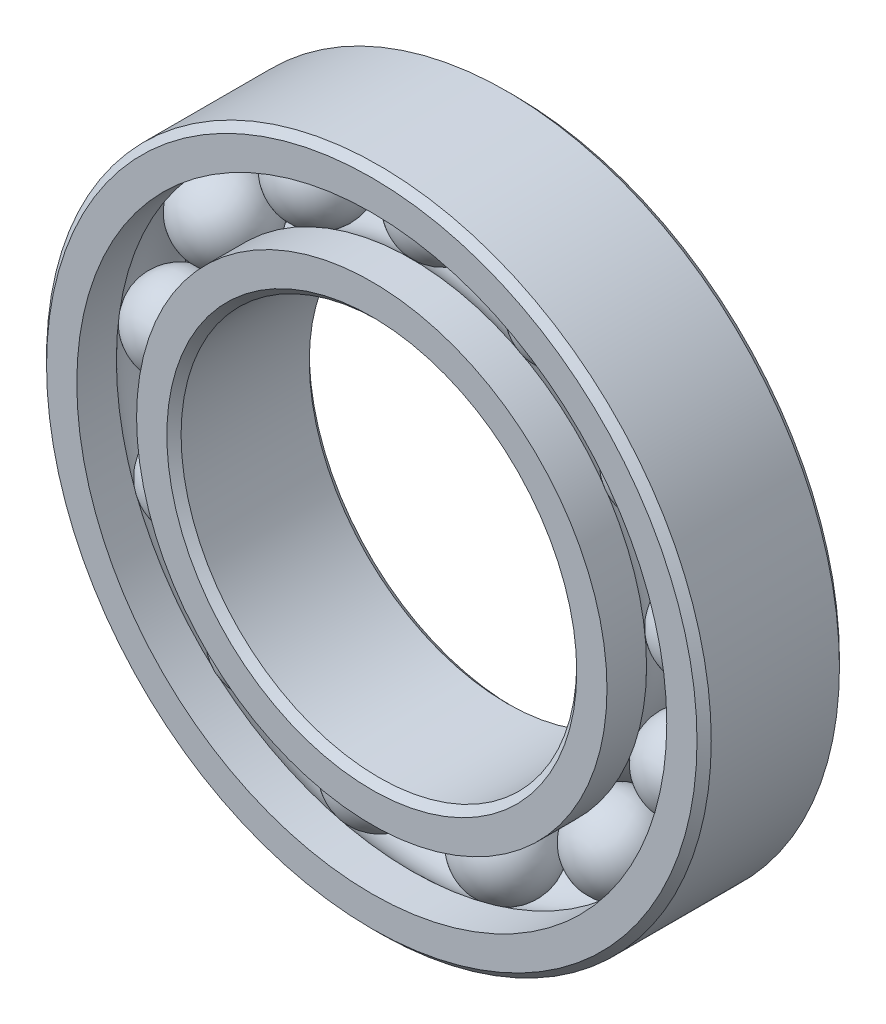
from build123d import *

# Parameters (mm, degrees)
CIRPATTERN1_COUNT = 13


with BuildPart() as part:
    # Sketch5 → Revolve1 (revolve)
    with BuildSketch(Plane(origin=(0, 0, 0), x_dir=(0, 0, -1), z_dir=(1, 0, 0))):
        with BuildLine():
            Line((4.05, 21), (-4.05, 21))
            Line((-4.05, 21), (-4.5, 20.55))
            Line((-4.5, 20.55), (-4.5, 18.638888889))
            Line((-4.5, 18.638888889), (-2, 18.638888889))
            ThreePointArc((-2, 18.638888889), (0, 19.500981867), (2, 18.638888889))
            Line((2, 18.638888889), (4.5, 18.638888889))
            Line((4.5, 18.638888889), (4.5, 20.55))
            Line((4.5, 20.55), (4.05, 21))
        make_face()
    revolve(axis=Axis((0, 0, 4.5), (0, 0, -1)))


with BuildPart() as body_2:
    # Sketch3 → Revolve3 (revolve)
    with BuildSketch(Plane(origin=(0, 0, 0), x_dir=(0, 0, -1), z_dir=(1, 0, 0))):
        with BuildLine():
            Line((-4.5, 14.861111111), (-2, 14.861111111))
            ThreePointArc((-2, 14.861111111), (0, 13.999018133), (2, 14.861111111))
            Line((2, 14.861111111), (4.5, 14.861111111))
            Line((4.5, 14.861111111), (4.5, 12.95))
            Line((4.5, 12.95), (4.05, 12.5))
            Line((4.05, 12.5), (-4.05, 12.5))
            Line((-4.05, 12.5), (-4.5, 12.95))
            Line((-4.5, 12.95), (-4.5, 14.861111111))
        make_face()
    revolve(axis=Axis((0, 0, 4.5), (0, 0, -1)))


with BuildPart() as body_3:
    # Sketch4 → Revolve4 (revolve)
    with BuildSketch(Plane(origin=(0, 0, 0), x_dir=(0, 0, -1), z_dir=(1, 0, 0))):
        with BuildLine():
            Line((-2.750981867, 16.75), (2.750981867, 16.75))
            ThreePointArc((2.750981867, 16.75), (0, 19.500981867), (-2.750981867, 16.75))
        make_face()
    revolve(axis=Axis((0, 16.75, 2.750981867), (0, 0, -1)))


with BuildPart() as cirpattern1_1:
    # CirPattern1: pattern copy
    add(body_3.part.rotate(Axis((0, 0, 0), (0, 0, 1)), 1 * 360 / CIRPATTERN1_COUNT))


with BuildPart() as cirpattern1_2:
    # CirPattern1: pattern copy
    add(body_3.part.rotate(Axis((0, 0, 0), (0, 0, 1)), 2 * 360 / CIRPATTERN1_COUNT))


with BuildPart() as cirpattern1_3:
    # CirPattern1: pattern copy
    add(body_3.part.rotate(Axis((0, 0, 0), (0, 0, 1)), 3 * 360 / CIRPATTERN1_COUNT))


with BuildPart() as cirpattern1_4:
    # CirPattern1: pattern copy
    add(body_3.part.rotate(Axis((0, 0, 0), (0, 0, 1)), 4 * 360 / CIRPATTERN1_COUNT))


with BuildPart() as cirpattern1_5:
    # CirPattern1: pattern copy
    add(body_3.part.rotate(Axis((0, 0, 0), (0, 0, 1)), 5 * 360 / CIRPATTERN1_COUNT))


with BuildPart() as cirpattern1_6:
    # CirPattern1: pattern copy
    add(body_3.part.rotate(Axis((0, 0, 0), (0, 0, 1)), 6 * 360 / CIRPATTERN1_COUNT))


with BuildPart() as cirpattern1_7:
    # CirPattern1: pattern copy
    add(body_3.part.rotate(Axis((0, 0, 0), (0, 0, 1)), 7 * 360 / CIRPATTERN1_COUNT))


with BuildPart() as cirpattern1_8:
    # CirPattern1: pattern copy
    add(body_3.part.rotate(Axis((0, 0, 0), (0, 0, 1)), 8 * 360 / CIRPATTERN1_COUNT))


with BuildPart() as cirpattern1_9:
    # CirPattern1: pattern copy
    add(body_3.part.rotate(Axis((0, 0, 0), (0, 0, 1)), 9 * 360 / CIRPATTERN1_COUNT))


with BuildPart() as cirpattern1_10:
    # CirPattern1: pattern copy
    add(body_3.part.rotate(Axis((0, 0, 0), (0, 0, 1)), 10 * 360 / CIRPATTERN1_COUNT))


with BuildPart() as cirpattern1_11:
    # CirPattern1: pattern copy
    add(body_3.part.rotate(Axis((0, 0, 0), (0, 0, 1)), 11 * 360 / CIRPATTERN1_COUNT))


with BuildPart() as cirpattern1_12:
    # CirPattern1: pattern copy
    add(body_3.part.rotate(Axis((0, 0, 0), (0, 0, 1)), 12 * 360 / CIRPATTERN1_COUNT))


solid = Compound([part.part, body_2.part, body_3.part, cirpattern1_1.part, cirpattern1_2.part, cirpattern1_3.part, cirpattern1_4.part, cirpattern1_5.part, cirpattern1_6.part, cirpattern1_7.part, cirpattern1_8.part, cirpattern1_9.part, cirpattern1_10.part, cirpattern1_11.part, cirpattern1_12.part])
